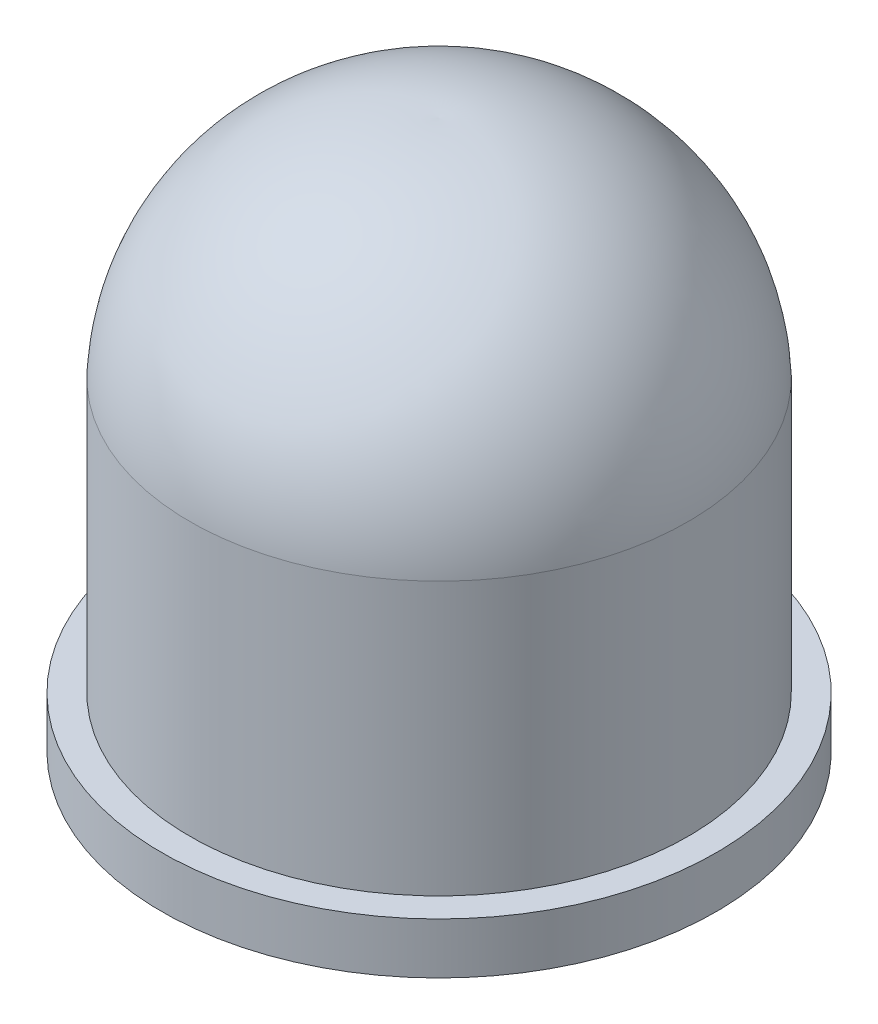
from build123d import *


with BuildPart() as part:
    # Sketch1 → Revolve3 (revolve)
    with BuildSketch(Plane.XY, mode=Mode.PRIVATE) as revolve3_sk:
        with BuildLine():
            Line((0, 0), (0, 5.840987161))
            ThreePointArc((0, 5.840987161), (1.821503375, 5.19115495), (2.65, 3.443656799))
            Line((2.65, 3.443656799), (2.65, 0.543656799))
            Line((2.65, 0.543656799), (2.95, 0.543656799))
            Line((2.95, 0.543656799), (2.95, 0))
            Line((2.95, 0), (0, 0))
        make_face()
    revolve(revolve3_sk.sketch.rotate(Axis((0, 0, 0), (0, 1, 0)), 90), axis=Axis((0, 0, 0), (0, 1, 0)))  # turned: the seam where the file's is


solid = part.part
